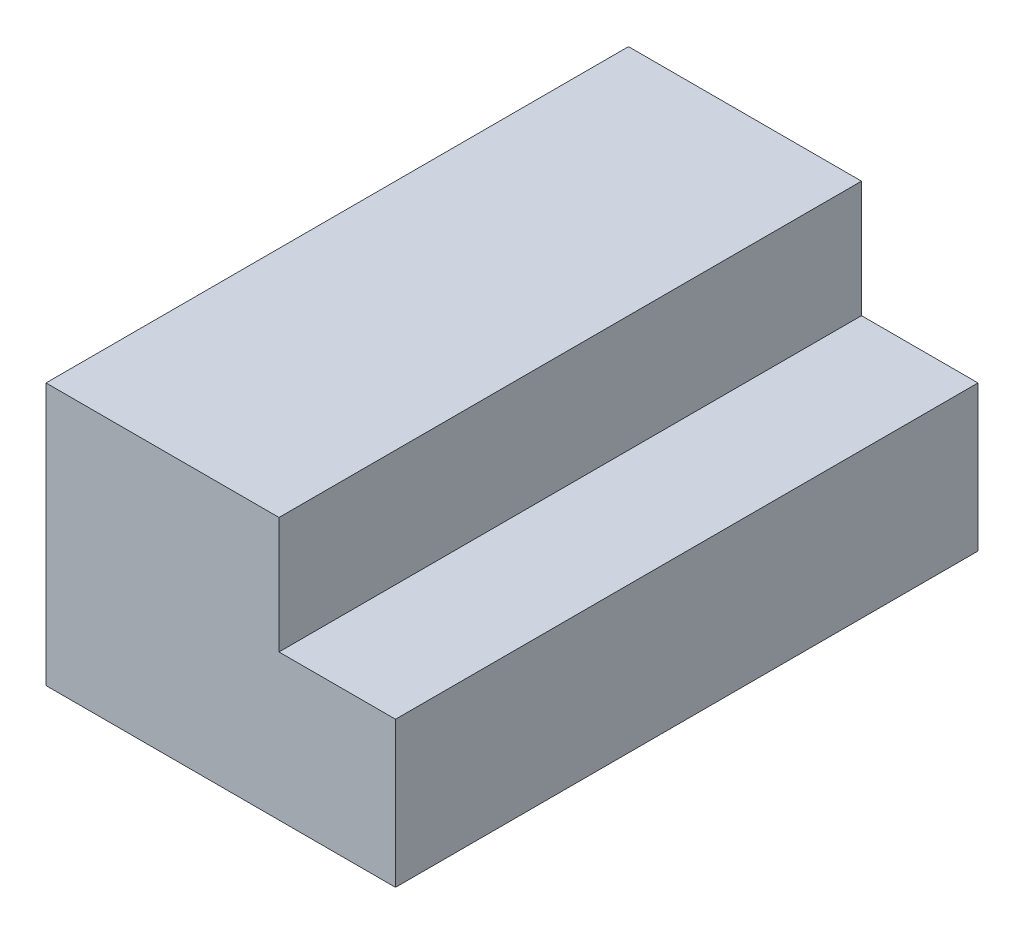
from build123d import *

# Parameters (mm, degrees)
BOSS_EXTRUDE1_DEPTH = 5


with BuildPart() as part:
    # Sketch1 → Boss-Extrude1 (new body)
    with BuildSketch(Plane.XY):
        Polygon((-2, 1), (0, 1), (0, 0), (1, 0), (1, -1.25), (-2, -1.25), align=None)
    extrude(amount=BOSS_EXTRUDE1_DEPTH)


solid = part.part
